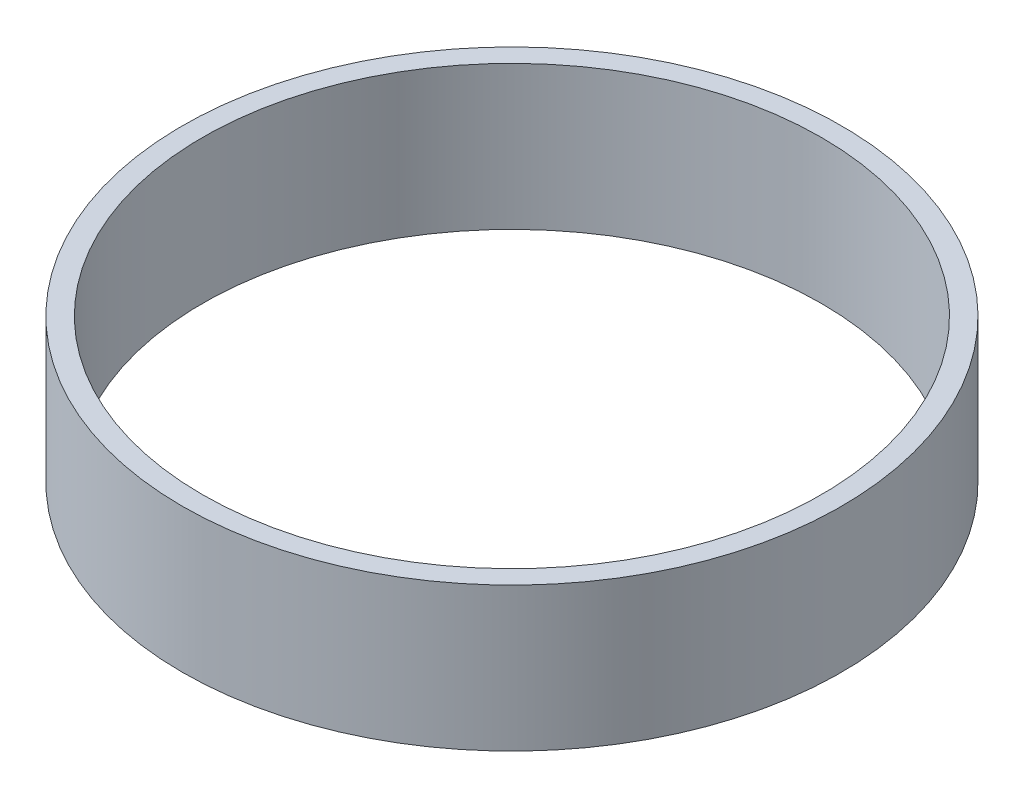
from build123d import *

# Parameters (mm, degrees)
SKETCH1_R           = 29.1084
SKETCH1_R_2         = 27.3304
BOSS_EXTRUDE1_DEPTH = 12.7


with BuildPart() as part:
    # Sketch1 → Boss-Extrude1 (new body)
    with BuildSketch(Plane(origin=(0, 0, 0), x_dir=(1, 0, 0), z_dir=(0, 1, 0))):
        Circle(SKETCH1_R)
        Circle(SKETCH1_R_2, mode=Mode.SUBTRACT)
    extrude(amount=BOSS_EXTRUDE1_DEPTH)


solid = part.part
